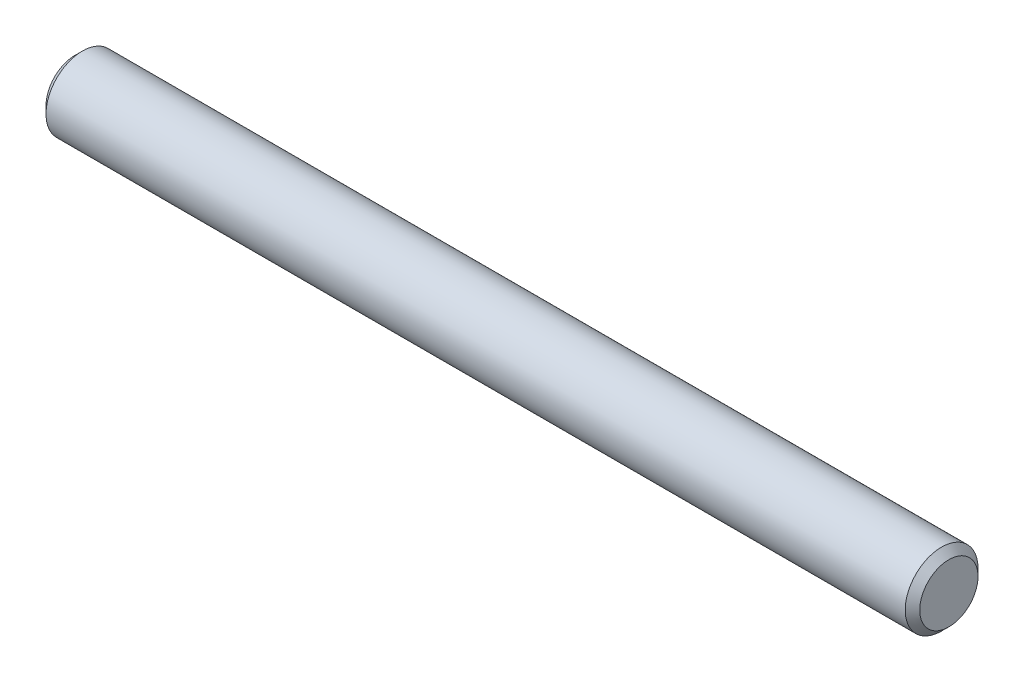
from build123d import *

# Parameters (mm, degrees)
SKETCH2_R           = 0.79375
EXTRUDE1_DEPTH      = 9.525
EXTRUDE1_DEPTH_BACK = 9.525
CHAMFER1_SIZE       = 0.15875


with BuildPart() as part:
    # Sketch2 → Extrude1 (new body, two sides)
    with BuildSketch(Plane(origin=(0, 0, 0), x_dir=(0, 0, -1), z_dir=(1, 0, 0))) as extrude1_sk:
        Circle(SKETCH2_R)
    extrude(amount=EXTRUDE1_DEPTH)
    extrude(extrude1_sk.sketch, amount=-EXTRUDE1_DEPTH_BACK)

    # Chamfer1
    chamfer1_edges = [part.edges().sort_by_distance(p)[0] for p in [
        (-9.525, 0, 0.79375),
        (9.525, 0, 0.79375),
    ]]
    chamfer(chamfer1_edges, length=CHAMFER1_SIZE)


solid = part.part
